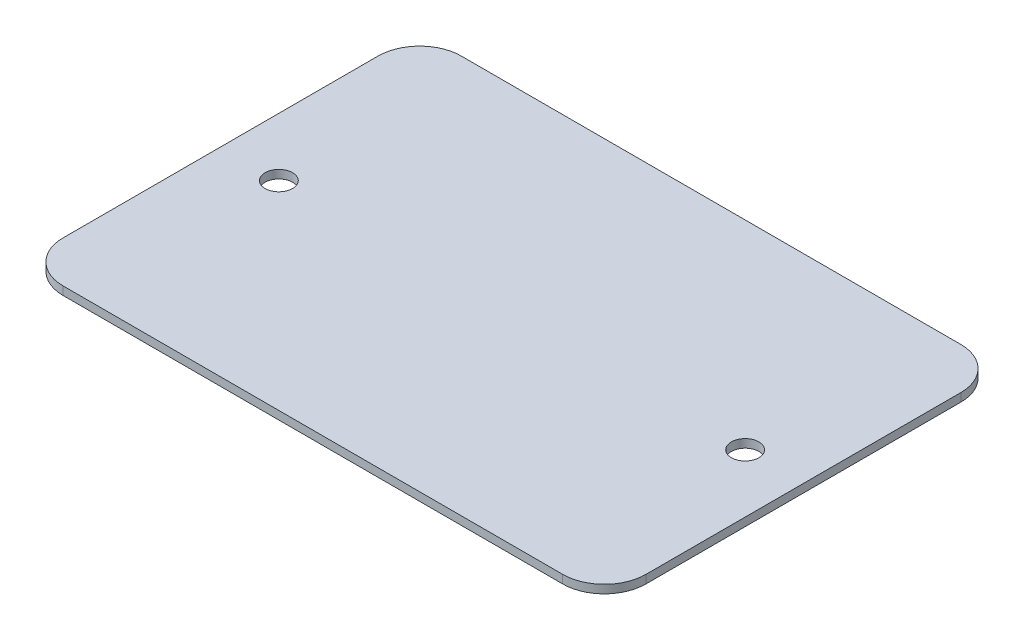
from build123d import *

# Parameters (mm, degrees)
CROQUIS1_W                = 70
CROQUIS1_H                = 47.820638631
SALIENTE_EXTRUIR1_DEPTH   = 1
REDONDEO1_R               = 5
TALADRO_ROSCADO_M41_D     = 3.3
TALADRO_ROSCADO_M41_DEPTH = 11.5
TALADRO_ROSCADO_M41_TIP   = 0.991420021


with BuildPart() as part:
    # Croquis1 → Saliente-Extruir1 (new body)
    with BuildSketch(Plane(origin=(0, 0, 0), x_dir=(1, 0, 0), z_dir=(0, 1, 0))):
        with Locations((-28.897022241, -11.598967779)):
            Rectangle(CROQUIS1_W, CROQUIS1_H)
    extrude(amount=SALIENTE_EXTRUIR1_DEPTH)

    # Redondeo1
    redondeo1_edges = [part.edges().sort_by_distance(p)[0] for p in [
        (6.102977759, 0.5, 35.509287094),
        (-63.897022241, 0.5, 35.509287094),
        (-63.897022241, 0.5, -12.311351537),
        (6.102977759, 0.5, -12.311351537),
    ]]
    fillet(redondeo1_edges, radius=REDONDEO1_R)

    # Taladro roscado M41
    with Locations(Plane(origin=(0, 1, 0), x_dir=(1, 0, 0), z_dir=(0, 1, 0))):
        with Locations((-56.897022241, -11.598967779), (-0.897022241, -11.598967779)):
            Hole(TALADRO_ROSCADO_M41_D / 2, depth=TALADRO_ROSCADO_M41_DEPTH)
            with Locations((0, 0, -(TALADRO_ROSCADO_M41_DEPTH + TALADRO_ROSCADO_M41_TIP / 2))):  # 118° drill point
                Cone(0, TALADRO_ROSCADO_M41_D / 2, TALADRO_ROSCADO_M41_TIP, mode=Mode.SUBTRACT)


solid = part.part
